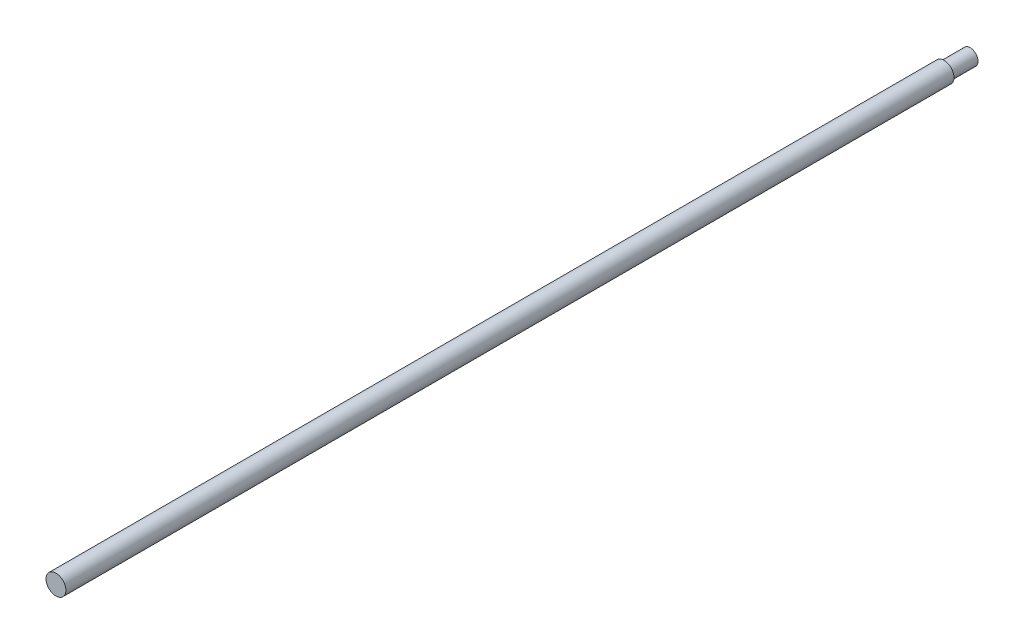
from build123d import *

# Parameters (mm, degrees)
SKETCH1_R           = 3.8
BOSS_EXTRUDE1_DEPTH = 350
SKETCH2_OUTSIDE_W   = 79.632
SKETCH2_OUTSIDE_H   = 79.632
SKETCH2_OUTSIDE_R   = 3
CUT_EXTRUDE1_DEPTH  = 10


with BuildPart() as part:
    # Sketch1 → Boss-Extrude1 (new body)
    with BuildSketch(Plane.XY):
        Circle(SKETCH1_R)
    extrude(amount=BOSS_EXTRUDE1_DEPTH)

    # Sketch2 outside → Cut-Extrude1 (cut)
    with BuildSketch(Plane(origin=(0, 0, 0), x_dir=(-1, 0, 0), z_dir=(0, 0, -1))):
        Rectangle(SKETCH2_OUTSIDE_W, SKETCH2_OUTSIDE_H)
        Circle(SKETCH2_OUTSIDE_R, mode=Mode.SUBTRACT)
    extrude(amount=-CUT_EXTRUDE1_DEPTH, mode=Mode.SUBTRACT)


solid = part.part
